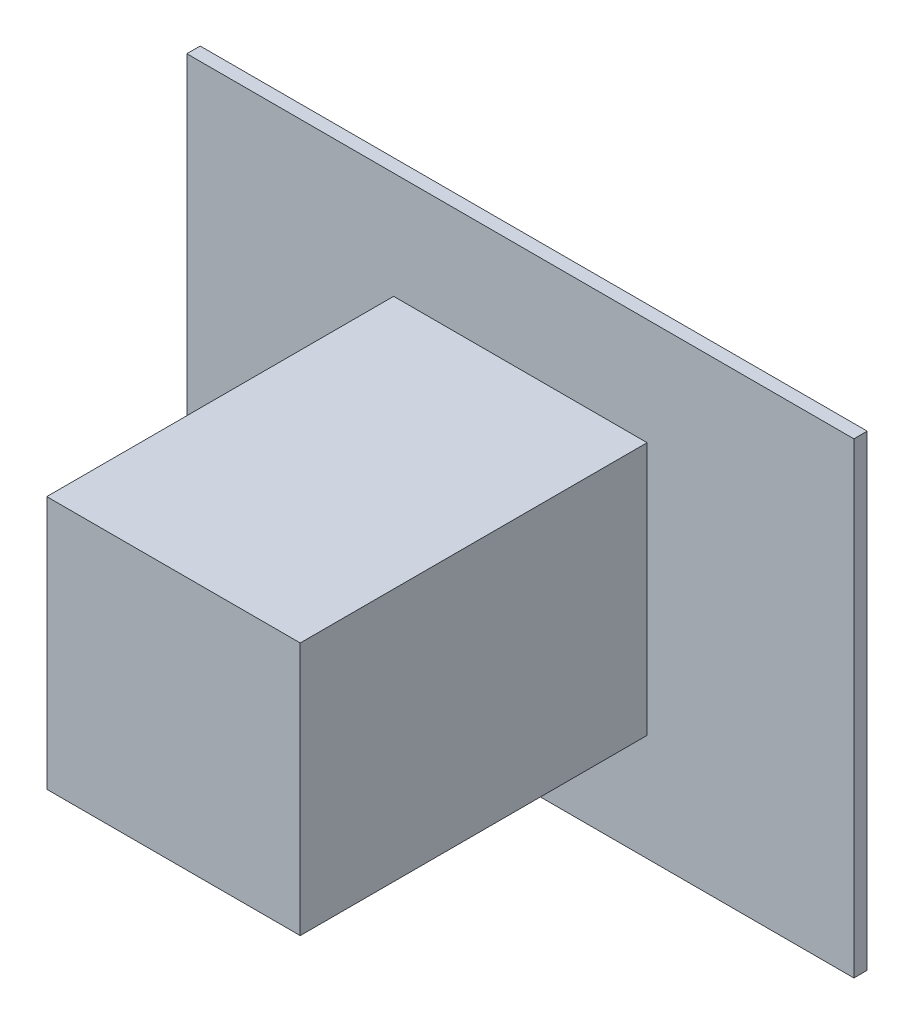
from build123d import *

# Parameters (mm, degrees)
SKETCH1_W           = 1.9
SKETCH1_H           = 1.9
BOSS_EXTRUDE1_DEPTH = 3
SKETCH4_W           = 5
SKETCH4_H           = 3.5
SKETCH4_W_2         = 1.530066542
SKETCH4_H_2         = 1.473797408
BOSS_EXTRUDE2_DEPTH = 0.1


with BuildPart() as part:
    # Sketch1 → Boss-Extrude1 (new body)
    with BuildSketch(Plane.XY):
        Rectangle(SKETCH1_W, SKETCH1_H)
    extrude(amount=BOSS_EXTRUDE1_DEPTH)

    # Sketch3 → Cut-Revolve1 (revolve, cut)
    with BuildSketch(Plane(origin=(0, 0, 0), x_dir=(0, 0, -1), z_dir=(1, 0, 0))):
        with BuildLine():
            Line((0, 0), (0, 0.7))
            Line((0, 0.7), (-0.972189278, 0.7))
            ThreePointArc((-0.972189278, 0.7), (-1.461166365, 0.49170934), (-1.662922441, 0))
            Line((-1.662922441, 0), (0, 0))
        make_face()
    revolve(axis=Axis((0, 0, 5.25), (0, 0, -1)), mode=Mode.SUBTRACT)

    # Sketch4 → Boss-Extrude2 (add)
    with BuildSketch(Plane(origin=(0, 0, 0.4), x_dir=(-1, 0, 0), z_dir=(0, 0, -1))):
        Rectangle(SKETCH4_W, SKETCH4_H)
        Rectangle(SKETCH4_W_2, SKETCH4_H_2, mode=Mode.SUBTRACT)
    extrude(amount=BOSS_EXTRUDE2_DEPTH)


solid = part.part
